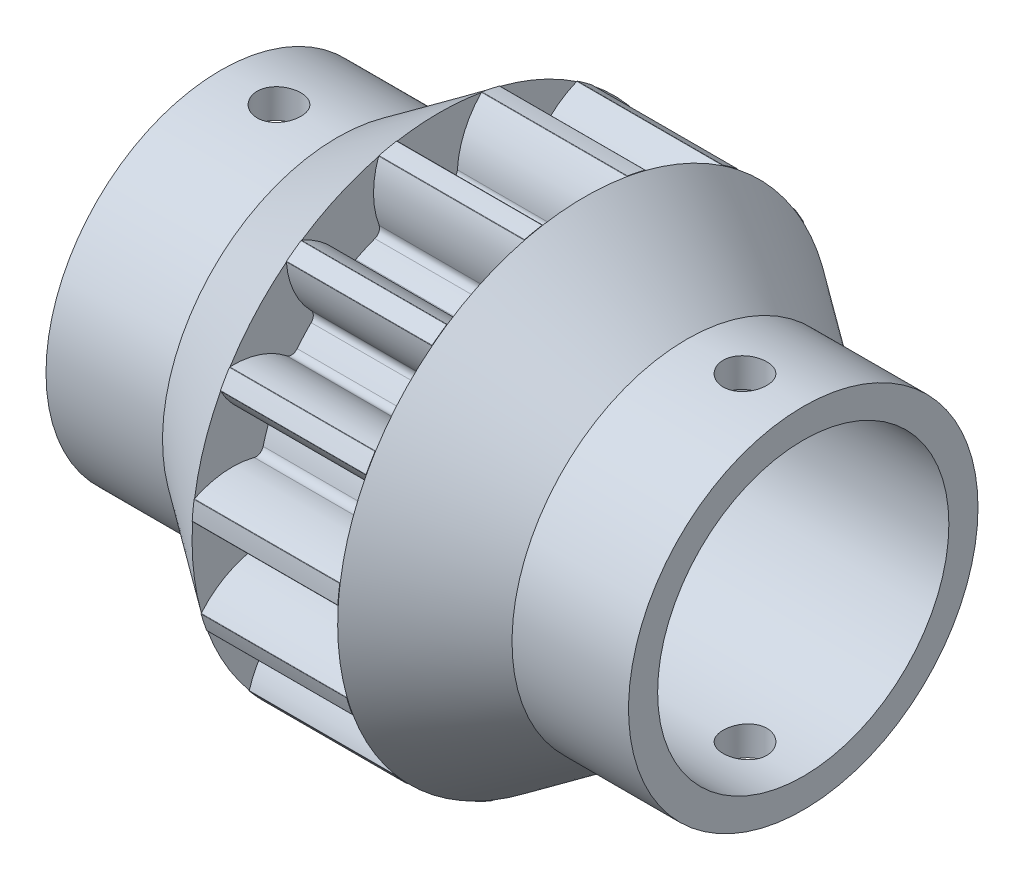
from build123d import *

# Parameters (mm, degrees)
BASPROSKE_W                   = 5
BASPROSKE_H                   = 8.5
TOOTHCUT_DEPTH                = 6
BREAKS_R                      = 0.02
ROOTFILLETS_R                 = 0.251
TEETHCUTS_COUNT               = 15
TEETHCUTS_ANGLE               = 336
BREAKS_OF_TEETHCUTS_R         = 0.02
ROOTFILLETS_OF_TEETHCUTS_R    = 0.251
HUBNEABOTSKE_R                = 6
HUBNEARBOTH_DEPTH             = 7.5000254
HUBFARSKE_R                   = 6
HUBFAR_DEPTH                  = 7.5000254
BORSKE_R                      = 5
BORE_DEPTH                    = 20.0000508
SCHIZZO8_R                    = 0.75
TAGLIO_ESTRUSIONE2_DEPTH      = 9.372849811
TAGLIO_ESTRUSIONE2_DEPTH_BACK = 9.5000001


with BuildPart() as part:
    # BasProSke → Base-Revolve (revolve)
    with BuildSketch(Plane(origin=(0, 0, 0), x_dir=(1, 0, 0), z_dir=(0, 1, 0))):
        with Locations((2.5, 4.25)):
            Rectangle(BASPROSKE_W, BASPROSKE_H)
    revolve(axis=Axis((-10, 0, 0), (1, 0, 0)))

    # TooCutSke → ToothCut (cut, through all)
    with BuildSketch(Plane(origin=(0, 0, 0), x_dir=(0, 0, -1), z_dir=(1, 0, 0))):
        with BuildLine():
            ThreePointArc((0.619547138, 6.21821215), (0, 6.249), (-0.619547138, 6.21821215))
            ThreePointArc((-0.619547138, 6.21821215), (-0.827197364, 7.394441061), (-1.477319646, 8.396426134))
            ThreePointArc((-1.477319646, 8.396426134), (0, 8.5254), (1.477319646, 8.396426134))
            ThreePointArc((1.477319646, 8.396426134), (0.827197364, 7.394441061), (0.619547138, 6.21821215))
        make_face()
    toothcut = extrude(amount=TOOTHCUT_DEPTH, mode=Mode.SUBTRACT)

    # Breaks
    breaks_edges = [part.edges().sort_by_distance(p)[0] for p in [
        (2.5, 8.374384951, -1.455910948),
        (2.5, 8.374384951, 1.455910948),
    ]]
    fillet(breaks_edges, radius=BREAKS_R)

    # RootFillets
    rootfillets_edges = [part.edges().sort_by_distance(p)[0] for p in [
        (2.5, 6.21821215, -0.619547138),
        (2.5, 6.21821215, 0.619547138),
    ]]
    fillet(rootfillets_edges, radius=ROOTFILLETS_R)

    # TeethCuts: ToothCut ×15 about axis
    teethcuts_axis = Axis((-10, 0, 0), (1, 0, 0))
    for i in range(1, TEETHCUTS_COUNT):
        add(toothcut.rotate(teethcuts_axis, i * TEETHCUTS_ANGLE / (TEETHCUTS_COUNT - 1)), mode=Mode.SUBTRACT)

    # Breaks of TeethCuts
    breaks_of_teethcuts_edges = [part.edges().sort_by_distance(p)[0] for p in [
        (2.5, 8.242553664, 2.076128389),
        (2.5, 7.058209001, 4.736210056),
        (2.5, 6.685509968, 5.249186267),
        (2.5, 4.521604593, 7.197575419),
        (2.5, 3.972480862, 7.514612153),
        (2.5, 1.203173673, 8.414414603),
        (2.5, 0.572573726, 8.480693328),
        (2.5, -2.323296905, 8.17632506),
        (2.5, -2.926336609, 7.980385583),
        (2.5, -5.448048342, 6.524474635),
        (2.5, -5.919256759, 6.100196671),
        (2.5, -7.630782727, 3.744483272),
        (2.5, -7.888683641, 3.165228336),
        (2.5, -8.494085455, 0.317036734),
        (2.5, -8.494085455, -0.317036734),
        (2.5, -7.888683641, -3.165228336),
        (2.5, -7.630782727, -3.744483272),
        (2.5, -5.919256759, -6.100196671),
        (2.5, -5.448048342, -6.524474635),
        (2.5, -2.926336609, -7.980385583),
        (2.5, -2.323296905, -8.17632506),
        (2.5, 0.572573726, -8.480693328),
        (2.5, 1.203173673, -8.414414603),
        (2.5, 3.972480862, -7.514612153),
        (2.5, 4.521604593, -7.197575419),
        (2.5, 6.685509968, -5.249186267),
        (2.5, 7.058209001, -4.736210056),
        (2.5, 8.242553664, -2.076128389),
    ]]
    fillet(breaks_of_teethcuts_edges, radius=BREAKS_OF_TEETHCUTS_R)

    # RootFillets of TeethCuts
    rootfillets_of_teethcuts_edges = [part.edges().sort_by_distance(p)[0] for p in [
        (2.5, 5.932611987, 1.963190262),
        (2.5, 5.428626941, 3.095159209),
        (2.5, 4.621209316, 4.206474231),
        (2.5, 3.700382817, 5.035590135),
        (2.5, 2.510757571, 5.722420591),
        (2.5, 1.332308887, 6.105321779),
        (2.5, -0.033826967, 6.248908444),
        (2.5, -1.266133354, 6.119387823),
        (2.5, -2.572562515, 5.694903257),
        (2.5, -3.645649635, 5.075356119),
        (2.5, -4.666478633, 4.156197561),
        (2.5, -5.394799975, 3.153749234),
        (2.5, -5.953518203, 1.898847548),
        (2.5, -6.211140388, 0.686830456),
        (2.5, -6.211140388, -0.686830456),
        (2.5, -5.953518203, -1.898847548),
        (2.5, -5.394799975, -3.153749234),
        (2.5, -4.666478633, -4.156197561),
        (2.5, -3.645649635, -5.075356119),
        (2.5, -2.572562515, -5.694903257),
        (2.5, -1.266133354, -6.119387823),
        (2.5, -0.033826967, -6.248908444),
        (2.5, 1.332308887, -6.105321779),
        (2.5, 2.510757571, -5.722420591),
        (2.5, 3.700382817, -5.035590135),
        (2.5, 4.621209316, -4.206474231),
        (2.5, 5.428626941, -3.095159209),
        (2.5, 5.932611987, -1.963190262),
    ]]
    fillet(rootfillets_of_teethcuts_edges, radius=ROOTFILLETS_OF_TEETHCUTS_R)

    # HubNeaBotSke → HubNearBoth (add)
    with BuildSketch(Plane.ZY):
        Circle(HUBNEABOTSKE_R)
    extrude(amount=HUBNEARBOTH_DEPTH)

    # HubFarSke → HubFar (add)
    with BuildSketch(Plane(origin=(5, 0, 0), x_dir=(0, 0, -1), z_dir=(1, 0, 0))):
        Circle(HUBFARSKE_R)
    extrude(amount=HUBFAR_DEPTH)

    # BorSke → Bore (cut, symmetric)
    with BuildSketch(Plane(origin=(0, 0, 0), x_dir=(0, 0, -1), z_dir=(1, 0, 0))):
        Circle(BORSKE_R)
    extrude(amount=BORE_DEPTH, both=True, mode=Mode.SUBTRACT)

    # Schizzo8 → Taglio-Estrusione2 (cut, two sides)
    with BuildSketch(Plane(origin=(0, 0, 0), x_dir=(1, 0, 0), z_dir=(0, 1, 0))) as taglio_estrusione2_sk:
        with Locations((-5.5000254, 0)):
            Circle(SCHIZZO8_R)
        with Locations((10.5000254, 0)):
            Circle(SCHIZZO8_R)
    extrude(amount=TAGLIO_ESTRUSIONE2_DEPTH, mode=Mode.SUBTRACT)
    extrude(taglio_estrusione2_sk.sketch, amount=-TAGLIO_ESTRUSIONE2_DEPTH_BACK, mode=Mode.SUBTRACT)

    # Schizzo9 → Rivoluzione1 (revolve)
    with BuildSketch(Plane.XY):
        Polygon((8.5000254, -6), (5, -8.484989935), (5, -6), align=None)
        Polygon((-3.5000254, -6), (0, -8.484989935), (0, -6), align=None)
    revolve(axis=Axis((12.5000254, 0, 0), (-1, 0, 0)))


solid = part.part
